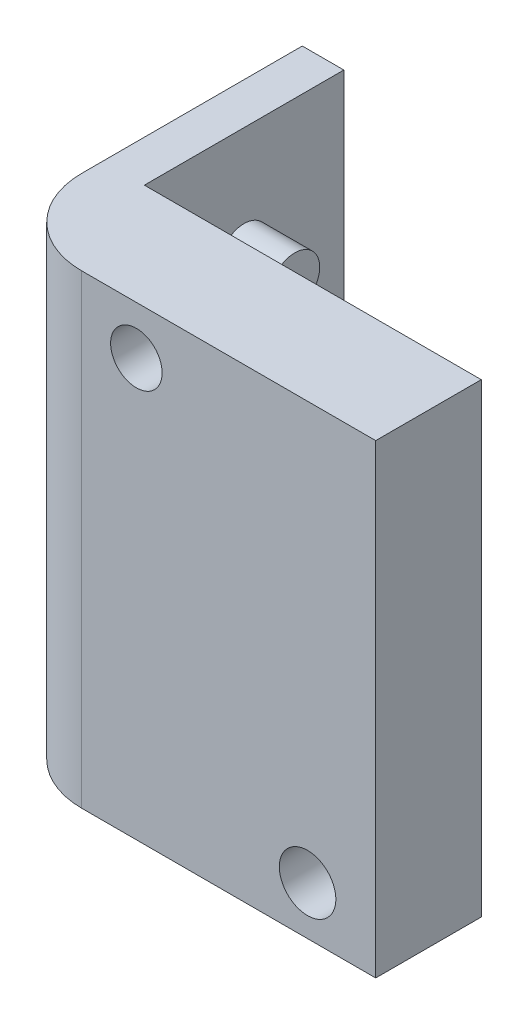
from build123d import *

# Parameters (mm, degrees)
BOSS_EXTRUDE1_DEPTH = 27.9999948
SKETCH2_R           = 1.5
CUT_EXTRUDE1_DEPTH  = 3.5
SKETCH2_4_R         = 1.5
BOSS_EXTRUDE3_DEPTH = 3.048
SKETCH3_R           = 1.55
SKETCH3_R_2         = 1.7
CUT_EXTRUDE2_DEPTH  = 19.35
SKETCH4_W           = 22.7671934
SKETCH4_H           = 27.9999948
CUT_EXTRUDE3_DEPTH  = 19.35
FILLET1_R           = 5.08


with BuildPart() as part:
    # Sketch1 → Boss-Extrude1 (new body)
    with BuildSketch(Plane(origin=(0, 0, 0), x_dir=(1, 0, 0), z_dir=(0, 1, 0))):
        Polygon((0, 18.35), (0, 0), (-22.7671934, 0), (-22.7671934, 6.35), (-2.5, 6.35), (-2.5, 18.35), align=None)
    boss_extrude1 = extrude(amount=BOSS_EXTRUDE1_DEPTH)

    # Sketch2 → Cut-Extrude1 (cut, through all)
    with BuildSketch(Plane.ZY.offset(2.5)):
        with Locations((-12.35, 6.4999997)):
            Circle(SKETCH2_R)
    cut_extrude1 = extrude(amount=-CUT_EXTRUDE1_DEPTH, mode=Mode.SUBTRACT)

    # Sketch2_4 → Boss-Extrude3 (add)
    with BuildSketch(Plane.ZY.offset(2.5)):
        with Locations((-12.35, 21.4999951)):
            Circle(SKETCH2_4_R)
    boss_extrude3 = extrude(amount=BOSS_EXTRUDE3_DEPTH)

    # Sketch3 → Cut-Extrude2 (cut, through all)
    with BuildSketch(Plane.XY):
        with Locations((-8.368, 25.0999974)):
            Circle(SKETCH3_R)
        with Locations((-18.668, 2.8999974)):
            Circle(SKETCH3_R_2)
    cut_extrude2 = extrude(amount=-CUT_EXTRUDE2_DEPTH, mode=Mode.SUBTRACT)

    # Mirror1: Boss-Extrude1, Cut-Extrude1, Boss-Extrude3, Cut-Extrude2 across plane
    add(boss_extrude1.mirror(Plane(origin=(0, 27.9999948, -18.35), x_dir=(0, 0, 1), z_dir=(-1, 0, 0))))
    add(cut_extrude1.mirror(Plane(origin=(0, 27.9999948, -18.35), x_dir=(0, 0, 1), z_dir=(-1, 0, 0))), mode=Mode.SUBTRACT)
    add(boss_extrude3.mirror(Plane(origin=(0, 27.9999948, -18.35), x_dir=(0, 0, 1), z_dir=(-1, 0, 0))))
    add(cut_extrude2.mirror(Plane(origin=(0, 27.9999948, -18.35), x_dir=(0, 0, 1), z_dir=(-1, 0, 0))), mode=Mode.SUBTRACT)

    # Sketch4 → Cut-Extrude3 (cut, through all)
    with BuildSketch(Plane.XY):
        with Locations((-11.3835967, 13.9999974)):
            Rectangle(SKETCH4_W, SKETCH4_H)
    extrude(amount=-CUT_EXTRUDE3_DEPTH, mode=Mode.SUBTRACT)

    # Fillet1
    fillet1_edges = [part.edges().sort_by_distance(p)[0] for p in [
        (0, 13.9999974, 0),
    ]]
    fillet(fillet1_edges, radius=FILLET1_R)


solid = part.part
